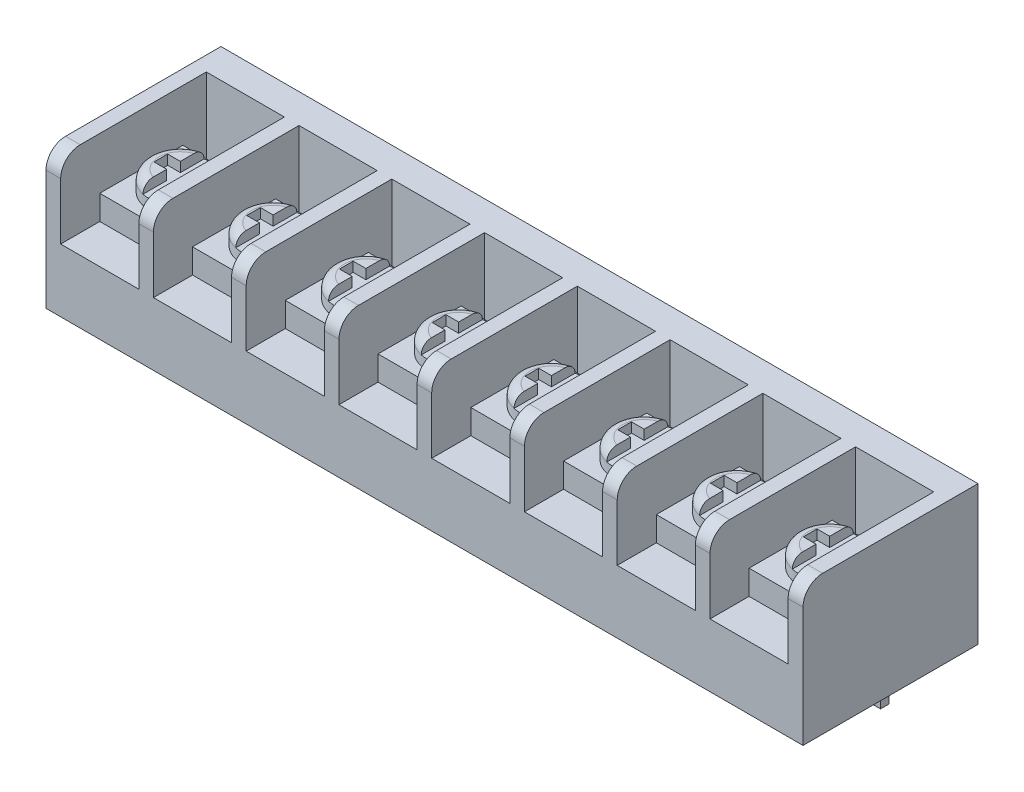
from build123d import *

# Parameters (mm, degrees)
SKETCH1_W             = 77.45
SKETCH1_H             = 17.9
BOSS_EXTRUDE1_DEPTH   = 14.25
FILLET1_R             = 2
SKETCH2_W             = 7.99375
SKETCH2_H             = 14.9
CUT_EXTRUDE1_DEPTH    = 7.8
SKETCH3_W             = 1.3
SKETCH3_H             = 0.85
BOSS_EXTRUDE2_DEPTH   = 5.6
BOSS_EXTRUDE2_2_DEPTH = 5.6
BOSS_EXTRUDE2_3_DEPTH = 5.6
BOSS_EXTRUDE2_4_DEPTH = 5.6
BOSS_EXTRUDE2_5_DEPTH = 5.6
BOSS_EXTRUDE2_6_DEPTH = 5.6
BOSS_EXTRUDE2_7_DEPTH = 5.6
BOSS_EXTRUDE2_8_DEPTH = 5.6
SKETCH4_W             = 7.99375
SKETCH4_H             = 8.5
BOSS_EXTRUDE3_DEPTH   = 2.5
BOSS_EXTRUDE3_2_DEPTH = 2.5
BOSS_EXTRUDE3_3_DEPTH = 2.5
BOSS_EXTRUDE3_4_DEPTH = 2.5
BOSS_EXTRUDE3_5_DEPTH = 2.5
BOSS_EXTRUDE3_6_DEPTH = 2.5
BOSS_EXTRUDE3_7_DEPTH = 2.5
BOSS_EXTRUDE3_8_DEPTH = 2.5
SKETCH5_R             = 3.2
BOSS_EXTRUDE4_DEPTH   = 2
CUT_EXTRUDE2_DEPTH    = 1
FILLET5_R             = 1
FILLET6_R             = 1
FILLET7_R             = 1
FILLET8_R             = 1
FILLET9_R             = 1
FILLET10_R            = 1
FILLET11_R            = 1
FILLET12_R            = 1


with BuildPart() as part:
    # Sketch1 → Boss-Extrude1 (new body)
    with BuildSketch(Plane(origin=(0, 0, 0), x_dir=(1, 0, 0), z_dir=(0, 1, 0))):
        Rectangle(SKETCH1_W, SKETCH1_H)
    extrude(amount=BOSS_EXTRUDE1_DEPTH)

    # Fillet1
    fillet1_edges = [part.edges().sort_by_distance(p)[0] for p in [
        (0, 14.25, 8.95),
    ]]
    fillet(fillet1_edges, radius=FILLET1_R)

    # Sketch2 → Cut-Extrude1 (cut)
    with BuildSketch(Plane(origin=(0, 14.25, 0), x_dir=(1, 0, 0), z_dir=(0, 1, 0))):
        with Locations((-33.228125, -1.5)):
            Rectangle(SKETCH2_W, SKETCH2_H)
        with Locations((-23.738125, -1.5)):
            Rectangle(SKETCH2_W, SKETCH2_H)
        with Locations((-14.248125, -1.5)):
            Rectangle(SKETCH2_W, SKETCH2_H)
        with Locations((-4.758125, -1.5)):
            Rectangle(SKETCH2_W, SKETCH2_H)
        with Locations((4.731875, -1.5)):
            Rectangle(SKETCH2_W, SKETCH2_H)
        with Locations((14.221875, -1.5)):
            Rectangle(SKETCH2_W, SKETCH2_H)
        with Locations((23.711875, -1.5)):
            Rectangle(SKETCH2_W, SKETCH2_H)
        with Locations((33.201875, -1.5)):
            Rectangle(SKETCH2_W, SKETCH2_H)
    extrude(amount=-CUT_EXTRUDE1_DEPTH, mode=Mode.SUBTRACT)


with BuildPart() as body_2:
    # Sketch3 → Boss-Extrude2 (new body)
    with BuildSketch(Plane.XZ):
        with Locations((-33.228125, -4.275)):
            Rectangle(SKETCH3_W, SKETCH3_H)
    extrude(amount=BOSS_EXTRUDE2_DEPTH)


with BuildPart() as body_3:
    # Sketch3 → Boss-Extrude2 2 (new body)
    with BuildSketch(Plane.XZ):
        with Locations((-23.738125, -4.275)):
            Rectangle(SKETCH3_W, SKETCH3_H)
    extrude(amount=BOSS_EXTRUDE2_2_DEPTH)


with BuildPart() as body_4:
    # Sketch3 → Boss-Extrude2 3 (new body)
    with BuildSketch(Plane.XZ):
        with Locations((-14.248125, -4.275)):
            Rectangle(SKETCH3_W, SKETCH3_H)
    extrude(amount=BOSS_EXTRUDE2_3_DEPTH)


with BuildPart() as body_5:
    # Sketch3 → Boss-Extrude2 4 (new body)
    with BuildSketch(Plane.XZ):
        with Locations((-4.758125, -4.275)):
            Rectangle(SKETCH3_W, SKETCH3_H)
    extrude(amount=BOSS_EXTRUDE2_4_DEPTH)


with BuildPart() as body_6:
    # Sketch3 → Boss-Extrude2 5 (new body)
    with BuildSketch(Plane.XZ):
        with Locations((4.731875, -4.275)):
            Rectangle(SKETCH3_W, SKETCH3_H)
    extrude(amount=BOSS_EXTRUDE2_5_DEPTH)


with BuildPart() as body_7:
    # Sketch3 → Boss-Extrude2 6 (new body)
    with BuildSketch(Plane.XZ):
        with Locations((14.221875, -4.275)):
            Rectangle(SKETCH3_W, SKETCH3_H)
    extrude(amount=BOSS_EXTRUDE2_6_DEPTH)


with BuildPart() as body_8:
    # Sketch3 → Boss-Extrude2 7 (new body)
    with BuildSketch(Plane.XZ):
        with Locations((23.711875, -4.275)):
            Rectangle(SKETCH3_W, SKETCH3_H)
    extrude(amount=BOSS_EXTRUDE2_7_DEPTH)


with BuildPart() as body_9:
    # Sketch3 → Boss-Extrude2 8 (new body)
    with BuildSketch(Plane.XZ):
        with Locations((33.201875, -4.275)):
            Rectangle(SKETCH3_W, SKETCH3_H)
    extrude(amount=BOSS_EXTRUDE2_8_DEPTH)


with BuildPart() as body_10:
    # Sketch4 → Boss-Extrude3 (new body)
    with BuildSketch(Plane(origin=(0, 6.45, 0), x_dir=(1, 0, 0), z_dir=(0, 1, 0))):
        with Locations((-33.228125, -0.7)):
            Rectangle(SKETCH4_W, SKETCH4_H)
    extrude(amount=BOSS_EXTRUDE3_DEPTH)

    # Sketch5 → Boss-Extrude4 (add)
    with BuildSketch(Plane(origin=(0, 8.95, 0), x_dir=(1, 0, 0), z_dir=(0, 1, 0))):
        with Locations((-33.228125, -0.7)):
            Circle(SKETCH5_R)
        with Locations((-23.738125, -0.7)):
            Circle(SKETCH5_R)
        with Locations((-14.248125, -0.7)):
            Circle(SKETCH5_R)
        with Locations((-4.758125, -0.7)):
            Circle(SKETCH5_R)
        with Locations((4.731875, -0.7)):
            Circle(SKETCH5_R)
        with Locations((14.221875, -0.7)):
            Circle(SKETCH5_R)
        with Locations((23.711875, -0.7)):
            Circle(SKETCH5_R)
        with Locations((33.201875, -0.7)):
            Circle(SKETCH5_R)
    extrude(amount=BOSS_EXTRUDE4_DEPTH)

    # Sketch6 → Cut-Extrude2 (cut)
    with BuildSketch(Plane(origin=(0, 10.95, 0), x_dir=(1, 0, 0), z_dir=(0, 1, 0))):
        Polygon((-33.928125, 2.5), (-33.928125, 0), (-35.228125, 0), (-35.228125, -1.4), (-33.928125, -1.4), (-33.928125, -3.9), (-32.528125, -3.9), (-32.528125, -1.4), (-31.228125, -1.4), (-31.228125, 0), (-32.528125, 0), (-32.528125, 2.5), align=None)
        Polygon((-23.038125, 2.5), (-24.438125, 2.5), (-24.438125, 0), (-25.738125, 0), (-25.738125, -1.4), (-24.438125, -1.4), (-24.438125, -3.9), (-23.038125, -3.9), (-23.038125, -1.4), (-21.738125, -1.4), (-21.738125, 0), (-23.038125, 0), align=None)
        Polygon((-13.548125, 2.5), (-14.948125, 2.5), (-14.948125, 0), (-16.248125, 0), (-16.248125, -1.4), (-14.948125, -1.4), (-14.948125, -3.9), (-13.548125, -3.9), (-13.548125, -1.4), (-12.248125, -1.4), (-12.248125, 0), (-13.548125, 0), align=None)
        Polygon((-4.058125, 2.5), (-5.458125, 2.5), (-5.458125, 0), (-6.758125, 0), (-6.758125, -1.4), (-5.458125, -1.4), (-5.458125, -3.9), (-4.058125, -3.9), (-4.058125, -1.4), (-2.758125, -1.4), (-2.758125, 0), (-4.058125, 0), align=None)
        Polygon((5.431875, 2.5), (4.031875, 2.5), (4.031875, 0), (2.731875, 0), (2.731875, -1.4), (4.031875, -1.4), (4.031875, -3.9), (5.431875, -3.9), (5.431875, -1.4), (6.731875, -1.4), (6.731875, 0), (5.431875, 0), align=None)
        Polygon((14.921875, 2.5), (13.521875, 2.5), (13.521875, 0), (12.221875, 0), (12.221875, -1.4), (13.521875, -1.4), (13.521875, -3.9), (14.921875, -3.9), (14.921875, -1.4), (16.221875, -1.4), (16.221875, 0), (14.921875, 0), align=None)
        Polygon((24.411875, 2.5), (23.011875, 2.5), (23.011875, 0), (21.711875, 0), (21.711875, -1.4), (23.011875, -1.4), (23.011875, -3.9), (24.411875, -3.9), (24.411875, -1.4), (25.711875, -1.4), (25.711875, 0), (24.411875, 0), align=None)
        Polygon((33.901875, 2.5), (32.501875, 2.5), (32.501875, 0), (31.201875, 0), (31.201875, -1.4), (32.501875, -1.4), (32.501875, -3.9), (33.901875, -3.9), (33.901875, -1.4), (35.201875, -1.4), (35.201875, 0), (33.901875, 0), align=None)
    extrude(amount=-CUT_EXTRUDE2_DEPTH, mode=Mode.SUBTRACT)

    # Fillet5
    fillet5_edges = [body_10.edges().sort_by_distance(p)[0] for p in [
        (-30.730125801, 10.95, -1.3),
        (-36.428125, 10.95, 0.7),
    ]]
    fillet(fillet5_edges, radius=FILLET5_R)

    # Fillet6
    fillet6_edges = [body_10.edges().sort_by_distance(p)[0] for p in [
        (-21.240125801, 10.95, -1.3),
        (-26.938125, 10.95, 0.7),
    ]]
    fillet(fillet6_edges, radius=FILLET6_R)

    # Fillet7
    fillet7_edges = [body_10.edges().sort_by_distance(p)[0] for p in [
        (-11.750125801, 10.95, -1.3),
        (-17.448125, 10.95, 0.7),
    ]]
    fillet(fillet7_edges, radius=FILLET7_R)

    # Fillet8
    fillet8_edges = [body_10.edges().sort_by_distance(p)[0] for p in [
        (-2.260125801, 10.95, -1.3),
        (-7.958125, 10.95, 0.7),
    ]]
    fillet(fillet8_edges, radius=FILLET8_R)

    # Fillet9
    fillet9_edges = [body_10.edges().sort_by_distance(p)[0] for p in [
        (7.229874199, 10.95, -1.3),
        (1.531875, 10.95, 0.7),
    ]]
    fillet(fillet9_edges, radius=FILLET9_R)

    # Fillet10
    fillet10_edges = [body_10.edges().sort_by_distance(p)[0] for p in [
        (16.719874199, 10.95, -1.3),
        (11.021875, 10.95, 0.7),
    ]]
    fillet(fillet10_edges, radius=FILLET10_R)

    # Fillet11
    fillet11_edges = [body_10.edges().sort_by_distance(p)[0] for p in [
        (26.209874199, 10.95, -1.3),
        (20.511875, 10.95, 0.7),
    ]]
    fillet(fillet11_edges, radius=FILLET11_R)

    # Fillet12
    fillet12_edges = [body_10.edges().sort_by_distance(p)[0] for p in [
        (35.699874199, 10.95, -1.3),
        (30.001875, 10.95, 0.7),
    ]]
    fillet(fillet12_edges, radius=FILLET12_R)


with BuildPart() as body_11:
    # Sketch4 → Boss-Extrude3 2 (new body)
    with BuildSketch(Plane(origin=(0, 6.45, 0), x_dir=(1, 0, 0), z_dir=(0, 1, 0))):
        with Locations((-23.738125, -0.7)):
            Rectangle(SKETCH4_W, SKETCH4_H)
    extrude(amount=BOSS_EXTRUDE3_2_DEPTH)


with BuildPart() as body_12:
    # Sketch4 → Boss-Extrude3 3 (new body)
    with BuildSketch(Plane(origin=(0, 6.45, 0), x_dir=(1, 0, 0), z_dir=(0, 1, 0))):
        with Locations((-14.248125, -0.7)):
            Rectangle(SKETCH4_W, SKETCH4_H)
    extrude(amount=BOSS_EXTRUDE3_3_DEPTH)


with BuildPart() as body_13:
    # Sketch4 → Boss-Extrude3 4 (new body)
    with BuildSketch(Plane(origin=(0, 6.45, 0), x_dir=(1, 0, 0), z_dir=(0, 1, 0))):
        with Locations((-4.758125, -0.7)):
            Rectangle(SKETCH4_W, SKETCH4_H)
    extrude(amount=BOSS_EXTRUDE3_4_DEPTH)


with BuildPart() as body_14:
    # Sketch4 → Boss-Extrude3 5 (new body)
    with BuildSketch(Plane(origin=(0, 6.45, 0), x_dir=(1, 0, 0), z_dir=(0, 1, 0))):
        with Locations((4.731875, -0.7)):
            Rectangle(SKETCH4_W, SKETCH4_H)
    extrude(amount=BOSS_EXTRUDE3_5_DEPTH)


with BuildPart() as body_15:
    # Sketch4 → Boss-Extrude3 6 (new body)
    with BuildSketch(Plane(origin=(0, 6.45, 0), x_dir=(1, 0, 0), z_dir=(0, 1, 0))):
        with Locations((14.221875, -0.7)):
            Rectangle(SKETCH4_W, SKETCH4_H)
    extrude(amount=BOSS_EXTRUDE3_6_DEPTH)


with BuildPart() as body_16:
    # Sketch4 → Boss-Extrude3 7 (new body)
    with BuildSketch(Plane(origin=(0, 6.45, 0), x_dir=(1, 0, 0), z_dir=(0, 1, 0))):
        with Locations((23.711875, -0.7)):
            Rectangle(SKETCH4_W, SKETCH4_H)
    extrude(amount=BOSS_EXTRUDE3_7_DEPTH)


with BuildPart() as body_17:
    # Sketch4 → Boss-Extrude3 8 (new body)
    with BuildSketch(Plane(origin=(0, 6.45, 0), x_dir=(1, 0, 0), z_dir=(0, 1, 0))):
        with Locations((33.201875, -0.7)):
            Rectangle(SKETCH4_W, SKETCH4_H)
    extrude(amount=BOSS_EXTRUDE3_8_DEPTH)


solid = Compound([part.part, body_2.part, body_3.part, body_4.part, body_5.part, body_6.part, body_7.part, body_8.part, body_9.part, body_10.part, body_11.part, body_12.part, body_13.part, body_14.part, body_15.part, body_16.part, body_17.part])
